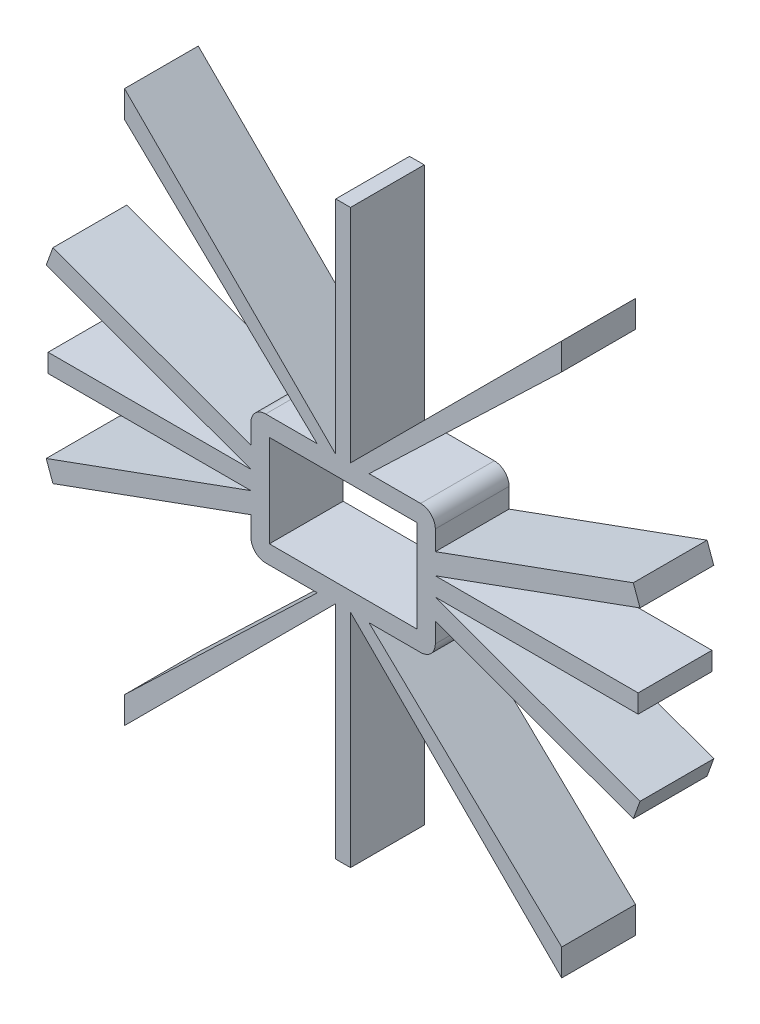
from build123d import *

# Parameters (mm, degrees)
SKETCH1_W           = 50.8
SKETCH1_H           = 31.75
BOSS_EXTRUDE1_DEPTH = 25.4
FILLET1_R           = 5.08


with BuildPart() as part:
    # Sketch1 → Boss-Extrude1 (new body)
    with BuildSketch(Plane.XY):
        Polygon((-101.6, -3.175), (-31.75, -3.175), (-102.245124878, -28.833127117), (-99.933913891, -35.183127117), (-31.75, -10.366212005), (-31.75, -22.225), (-8.889749428, -22.225), (-75.27486339, -85.781410988), (-75.27486339, -95.016274378), (-2.54, -22.281410988), (-2.54, -98.481410988), (2.54, -98.481410988), (2.54, -22.281410988), (75.27486339, -95.016274378), (75.27486339, -85.781410988), (8.889749428, -22.225), (31.75, -22.225), (31.75, -10.366212005), (99.933913891, -35.183127117), (102.245124878, -28.833127117), (31.75, -3.175), (101.6, -3.175), (101.6, 3.175), (31.75, 3.175), (102.245124878, 28.833127117), (99.933913891, 35.183127117), (31.75, 10.366212005), (31.75, 22.225), (8.948671098, 22.225), (75.27486339, 85.725), (75.27486339, 94.95986339), (2.54, 22.225), (2.54, 98.425), (-2.54, 98.425), (-2.54, 22.225), (-75.27486339, 94.95986339), (-75.27486339, 85.725), (-8.948671098, 22.225), (-31.75, 22.225), (-31.75, 10.366212005), (-99.933913891, 35.183127117), (-102.245124878, 28.833127117), (-31.75, 3.175), (-101.6, 3.175), align=None)
        Rectangle(SKETCH1_W, SKETCH1_H, mode=Mode.SUBTRACT)
    extrude(amount=BOSS_EXTRUDE1_DEPTH)

    # Fillet1
    fillet1_edges = [part.edges().sort_by_distance(p)[0] for p in [
        (31.75, -22.225, 12.7),
        (-31.75, -22.225, 12.7),
        (-31.75, 22.225, 12.7),
        (31.75, 22.225, 12.7),
    ]]
    fillet(fillet1_edges, radius=FILLET1_R)


solid = part.part
